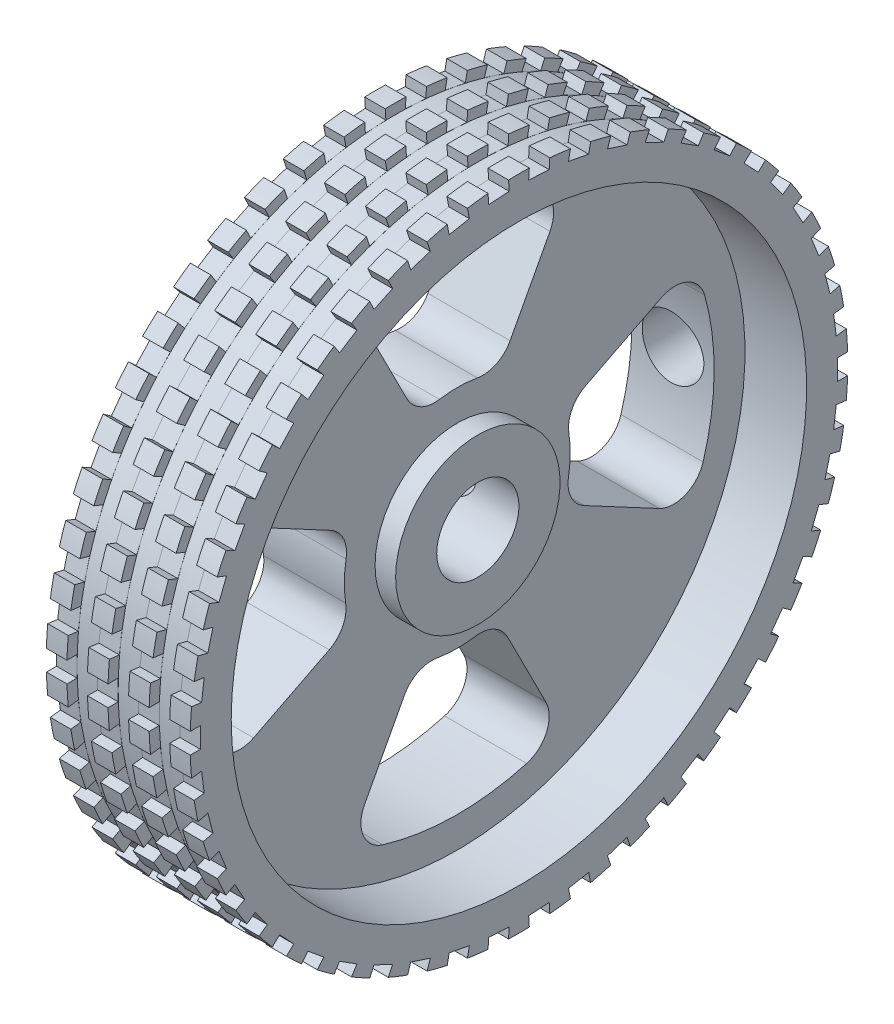
from build123d import *

# Parameters (mm, degrees)
CUT_EXTRUDE1_DEPTH       = 5.0000001
FILLET1_R                = 1.5
CIRPATTERN1_COUNT        = 4
FILLET1_OF_CIRPATTERN1_R = 1.5
SKETCH5_W                = 1
SKETCH5_H                = 0.5
SKETCH6_W                = 0.5
SKETCH6_H                = 1
CUT_EXTRUDE5_DEPTH       = 8.0000001
CIRPATTERN2_COUNT        = 50
LPATTERN1_COUNT          = 3
LPATTERN1_PITCH          = 2


with BuildPart() as part:
    # Sketch1 → Revolve1 (revolve)
    with BuildSketch(Plane.XY):
        Polygon((0, 16), (7, 16), (7, 14), (4, 14), (4, 4), (5, 4), (5, 2), (0, 2), align=None)
    revolve(axis=Axis((0, 0, 0), (1, 0, 0)))

    # Sketch3 → Cut-Revolve1 (revolve, cut)
    with BuildSketch(Plane(origin=(0, 0, 0), x_dir=(1, 0, 0), z_dir=(0, 1, 0))):
        Polygon((2, 0), (2, 16), (3.5, 16), (3.5, 11.5), (2.9, 11.5), (2.9, 0), align=None)
    revolve(axis=Axis((2, 0, 0), (0, 0, -1)), mode=Mode.SUBTRACT)

    # Sketch4 → Cut-Extrude1 (cut, through all)
    with BuildSketch(Plane(origin=(4, 0, 0), x_dir=(0, 0, -1), z_dir=(1, 0, 0))):
        with BuildLine():
            Line((-1.898878281, 5.161807946), (-5.076978261, 11.422534383))
            ThreePointArc((-5.076978261, 11.422534383), (0.127956777, 12.499345065), (5.309756517, 11.316204564))
            Line((5.309756517, 11.316204564), (2.004152918, 5.12185231))
            ThreePointArc((2.004152918, 5.12185231), (0.056300982, 5.499711829), (-1.898878281, 5.161807946))
        make_face()
    cut_extrude1 = extrude(amount=-CUT_EXTRUDE1_DEPTH, mode=Mode.SUBTRACT)

    # Fillet1
    fillet1_edges = [part.edges().sort_by_distance(p)[0] for p in [
        (2, 5.12185231, -2.004152918),
        (2, 5.161807946, 1.898878281),
        (2, 11.422534383, 5.076978261),
        (2, 11.316204564, -5.309756517),
    ]]
    fillet(fillet1_edges, radius=FILLET1_R)

    # CirPattern1: Cut-Extrude1 ×4 about axis
    cirpattern1_axis = Axis((0, 0, 0), (1, 0, 0))
    for i in range(1, CIRPATTERN1_COUNT):
        add(cut_extrude1.rotate(cirpattern1_axis, i * 360 / CIRPATTERN1_COUNT), mode=Mode.SUBTRACT)

    # Fillet1 of CirPattern1
    fillet1_of_cirpattern1_edges = [part.edges().sort_by_distance(p)[0] for p in [
        (2, 2.004152918, 5.12185231),
        (2, -1.898878281, 5.161807946),
        (2, -5.076978261, 11.422534383),
        (2, 5.309756517, 11.316204564),
        (2, -5.12185231, 2.004152918),
        (2, -5.161807946, -1.898878281),
        (2, -11.422534383, -5.076978261),
        (2, -11.316204564, 5.309756517),
        (2, -2.004152918, -5.12185231),
        (2, 1.898878281, -5.161807946),
        (2, 5.076978261, -11.422534383),
        (2, -5.309756517, -11.316204564),
    ]]
    fillet(fillet1_of_cirpattern1_edges, radius=FILLET1_OF_CIRPATTERN1_R)

    # Sketch5 → Cut-Revolve2 (revolve, cut)
    with BuildSketch(Plane.XY):
        with Locations((1.5, 15.75)):
            Rectangle(SKETCH5_W, SKETCH5_H)
    cut_revolve2 = revolve(axis=Axis((0, 0, 0), (1, 0, 0)), mode=Mode.SUBTRACT)

    # Sketch6 → Cut-Extrude5 (cut, through all)
    with BuildSketch(Plane(origin=(0, 0, 0), x_dir=(0, 0, -1), z_dir=(1, 0, 0))):
        with Locations((15.75, 0)):
            Rectangle(SKETCH6_W, SKETCH6_H)
    cut_extrude5 = extrude(amount=CUT_EXTRUDE5_DEPTH, mode=Mode.SUBTRACT)

    # CirPattern2: Cut-Extrude5 ×50 about axis
    cirpattern2_axis = Axis((0, 0, 0), (1, 0, 0))
    for i in range(1, CIRPATTERN2_COUNT):
        add(cut_extrude5.rotate(cirpattern2_axis, i * 360 / CIRPATTERN2_COUNT), mode=Mode.SUBTRACT)

    # LPattern1: Cut-Revolve2 ×3
    with Locations(*[(i * LPATTERN1_PITCH, 0, 0) for i in range(1, LPATTERN1_COUNT)]):
        add(cut_revolve2, mode=Mode.SUBTRACT)


solid = part.part
